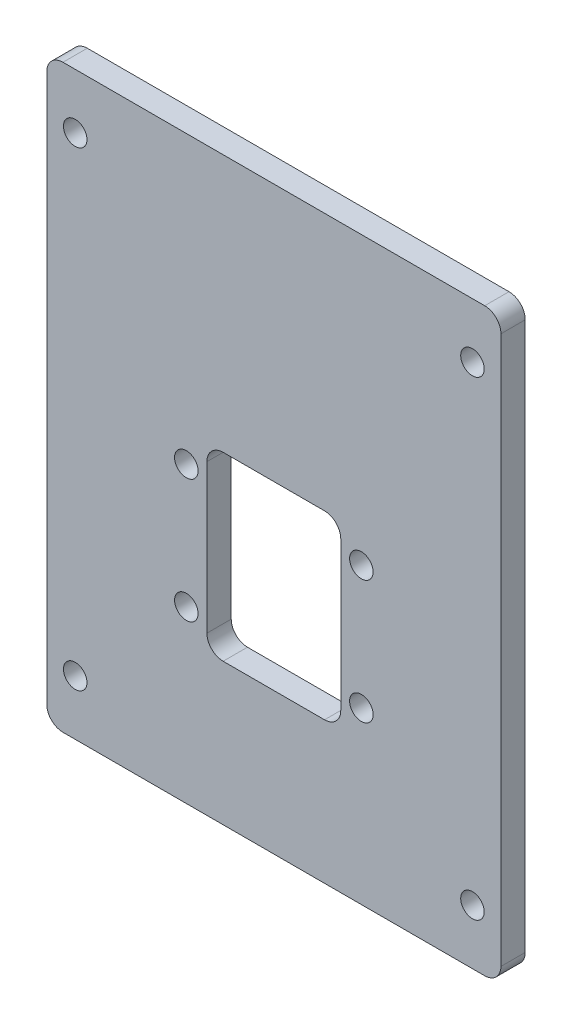
from build123d import *

# Parameters (mm, degrees)
SKETCH1_W           = 56.02
SKETCH1_H           = 71.58
SKETCH1_R           = 1.45
SKETCH1_W_2         = 16.51
SKETCH1_H_2         = 22.32
BOSS_EXTRUDE1_DEPTH = 3
FILLET1_R           = 2


with BuildPart() as part:
    # Sketch1 → Boss-Extrude1 (new body)
    with BuildSketch(Plane.XY):
        with Locations((0, 7.16)):
            Rectangle(SKETCH1_W, SKETCH1_H)
        with Locations((-10.795, -7.62)):
            Circle(SKETCH1_R, mode=Mode.SUBTRACT)
        with Locations((-10.795, 7.62)):
            Circle(SKETCH1_R, mode=Mode.SUBTRACT)
        with Locations((10.795, 7.62)):
            Circle(SKETCH1_R, mode=Mode.SUBTRACT)
        with Locations((10.795, -7.62)):
            Circle(SKETCH1_R, mode=Mode.SUBTRACT)
        with Locations((24.5, -21.84)):
            Circle(SKETCH1_R, mode=Mode.SUBTRACT)
        with Locations((-24.5, 36.16)):
            Circle(SKETCH1_R, mode=Mode.SUBTRACT)
        with Locations((-24.5, -21.84)):
            Circle(SKETCH1_R, mode=Mode.SUBTRACT)
        with Locations((24.5, 36.16)):
            Circle(SKETCH1_R, mode=Mode.SUBTRACT)
        Rectangle(SKETCH1_W_2, SKETCH1_H_2, mode=Mode.SUBTRACT)
    extrude(amount=BOSS_EXTRUDE1_DEPTH)

    # Fillet1
    fillet1_edges = [part.edges().sort_by_distance(p)[0] for p in [
        (-8.255, 11.16, 1.5),
        (-8.255, -11.16, 1.5),
        (8.255, -11.16, 1.5),
        (8.255, 11.16, 1.5),
        (-28.01, 42.95, 1.5),
        (28.01, 42.95, 1.5),
        (28.01, -28.63, 1.5),
        (-28.01, -28.63, 1.5),
    ]]
    fillet(fillet1_edges, radius=FILLET1_R)


solid = part.part
